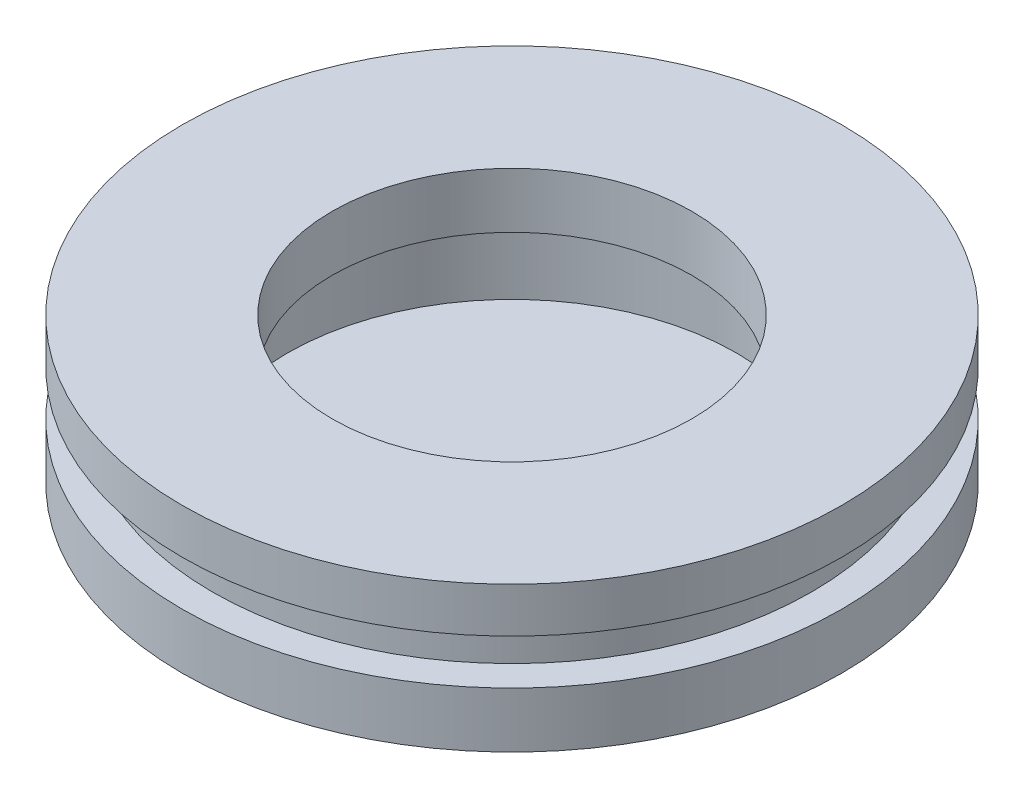
from build123d import *


with BuildPart() as part:
    # Sketch1 → Revolve1 (revolve)
    with BuildSketch(Plane.XY):
        Polygon((0, 0), (0, 8.853672577), (-11, 8.853672577), (-11, 7.353672577), (-10, 7.353672577), (-10, 5.853672577), (-11, 5.853672577), (-11, 4.003672577), align=None)
    revolve(axis=Axis((0, 0, 0), (0, 1, 0)))

    # Sketch2 → Cut-Revolve1 (revolve, cut)
    with BuildSketch(Plane.XY):
        Polygon((0, 4.003672577), (0, 10.003672577), (-6, 10.003672577), (-6, 7.003672577), (-7.5, 7.003672577), (-7.5, 4.003672577), align=None)
    revolve(axis=Axis((0, 4.003672577, 0), (0, 1, 0)), mode=Mode.SUBTRACT)


solid = part.part
